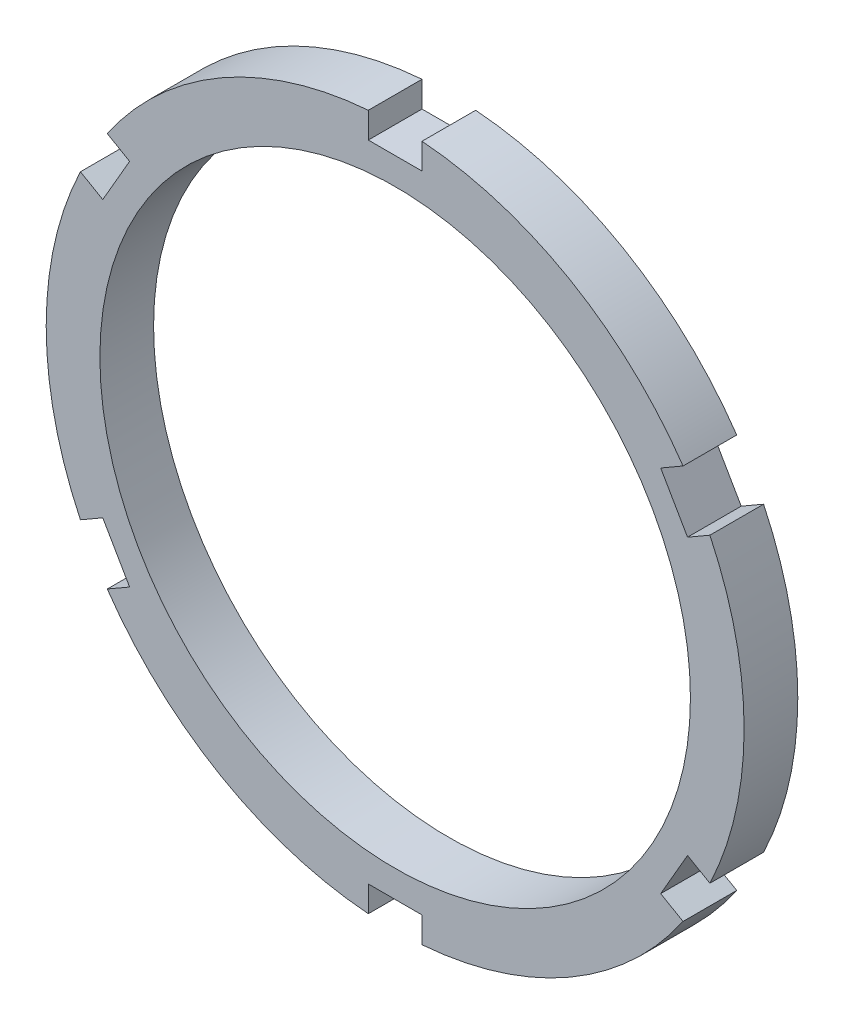
from build123d import *

# Parameters (mm, degrees)
SKETCH1_R           = 65
BOSS_EXTRUDE1_DEPTH = 10
SKETCH2_R           = 55
CUT_EXTRUDE1_DEPTH  = 11
SKETCH3_W           = 10
SKETCH3_H           = 5
CUT_EXTRUDE4_DEPTH  = 11


with BuildPart() as part:
    # Sketch1 → Boss-Extrude1 (new body)
    with BuildSketch(Plane.XY):
        Circle(SKETCH1_R)
    extrude(amount=BOSS_EXTRUDE1_DEPTH)

    # Sketch2 → Cut-Extrude1 (cut, through all)
    with BuildSketch(Plane.XY.offset(10)):
        Circle(SKETCH2_R)
    extrude(amount=-CUT_EXTRUDE1_DEPTH, mode=Mode.SUBTRACT)

    # Sketch3 → Cut-Extrude4 (cut, through all)
    with BuildSketch(Plane.XY.offset(10)):
        Polygon((49.461524227, 34.330127019), (53.791651246, 36.830127019), (58.791651246, 28.169872981), (54.461524227, 25.669872981), align=None)
        with Locations((0, 62.5)):
            Rectangle(SKETCH3_W, SKETCH3_H)
        Polygon((54.461524227, -25.669872981), (58.791651246, -28.169872981), (53.791651246, -36.830127019), (49.461524227, -34.330127019), align=None)
        with Locations((0, -62.5)):
            Rectangle(SKETCH3_W, SKETCH3_H)
        Polygon((-49.461524227, -34.330127019), (-53.791651246, -36.830127019), (-58.791651246, -28.169872981), (-54.461524227, -25.669872981), align=None)
        Polygon((-54.461524227, 25.669872981), (-58.791651246, 28.169872981), (-53.791651246, 36.830127019), (-49.461524227, 34.330127019), align=None)
    extrude(amount=-CUT_EXTRUDE4_DEPTH, mode=Mode.SUBTRACT)


solid = part.part
